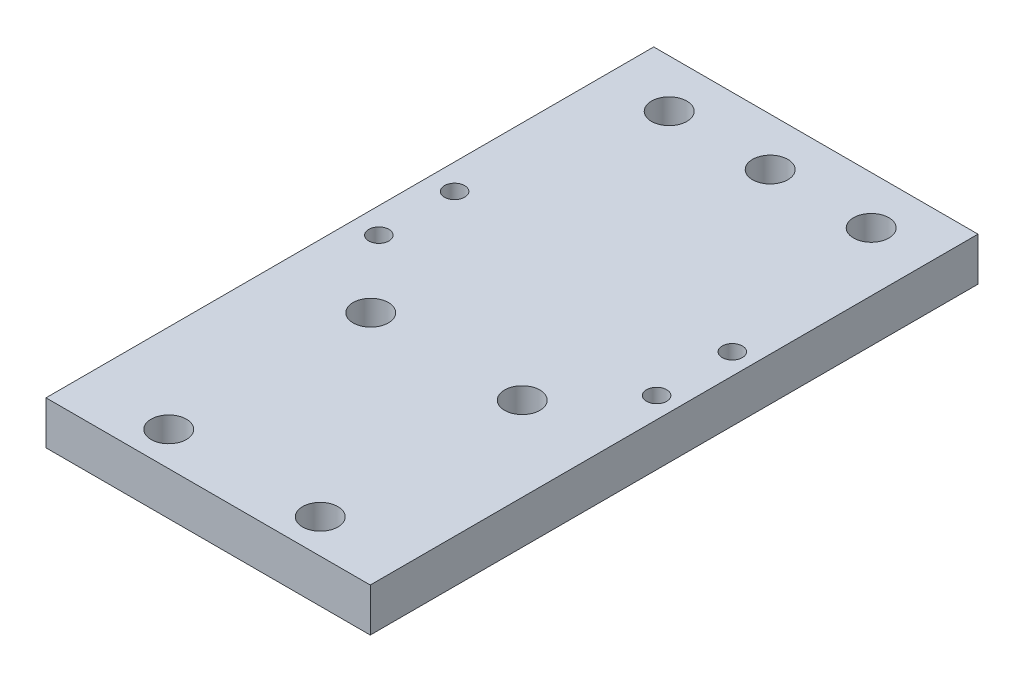
from build123d import *

# Parameters (mm, degrees)
SKETCH1_W           = 32.1056
SKETCH1_H           = 60.1726
BOSS_EXTRUDE1_DEPTH = 4.2926
SKETCH2_R           = 1.75
SKETCH2_R_2         = 1
CUT_EXTRUDE1_DEPTH  = 5.2926


with BuildPart() as part:
    # Sketch1 → Boss-Extrude1 (new body)
    with BuildSketch(Plane(origin=(0, 0, 0), x_dir=(1, 0, 0), z_dir=(0, 1, 0))):
        with Locations((0, 30.0863)):
            Rectangle(SKETCH1_W, SKETCH1_H)
    extrude(amount=BOSS_EXTRUDE1_DEPTH)

    # Sketch2 → Cut-Extrude1 (cut, through all)
    with BuildSketch(Plane(origin=(0, 4.2926, 0), x_dir=(1, 0, 0), z_dir=(0, 1, 0))):
        with Locations((-9.772224543, 55.4226)):
            Circle(SKETCH2_R)
        with Locations((0.227775457, 55.4226)):
            Circle(SKETCH2_R)
        with Locations((10.227775457, 55.4226)):
            Circle(SKETCH2_R)
        with Locations((-7.272224543, 3.3726)):
            Circle(SKETCH2_R)
        with Locations((-7.272224543, 23.3726)):
            Circle(SKETCH2_R)
        with Locations((7.727775457, 23.3726)):
            Circle(SKETCH2_R)
        with Locations((7.727775457, 3.3726)):
            Circle(SKETCH2_R)
        with Locations((13.977775457, 30.4226)):
            Circle(SKETCH2_R_2)
        with Locations((13.977775457, 37.9226)):
            Circle(SKETCH2_R_2)
        with Locations((-13.522224543, 37.9226)):
            Circle(SKETCH2_R_2)
        with Locations((-13.522224543, 30.4226)):
            Circle(SKETCH2_R_2)
    extrude(amount=-CUT_EXTRUDE1_DEPTH, mode=Mode.SUBTRACT)


solid = part.part
